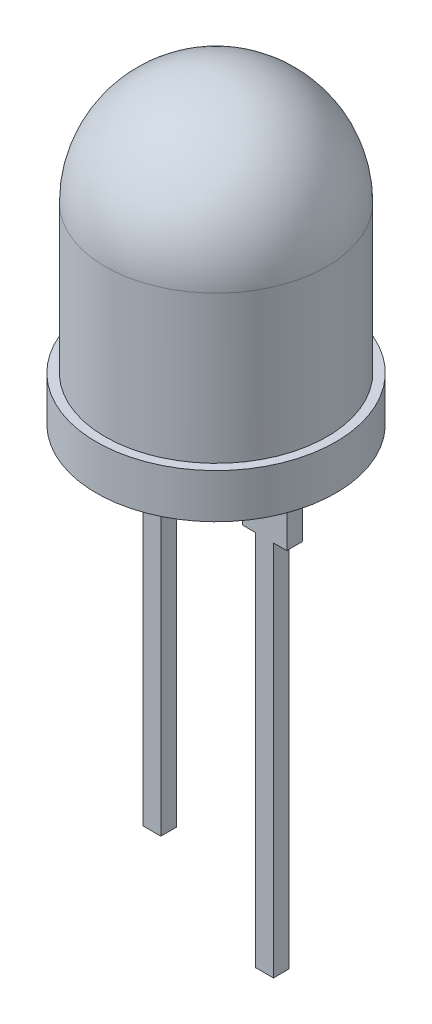
from build123d import *

# Parameters (mm, degrees)
BOSS_EXTRUDE1_DEPTH = 0.35


with BuildPart() as part:
    # Sketch1 → Revolve1 (revolve)
    with BuildSketch(Plane.XY):
        with BuildLine():
            Line((0, 0), (5.4, 0))
            Line((5.4, 0), (5.4, 2))
            Line((5.4, 2), (5, 2))
            Line((5, 2), (5, 8.65))
            ThreePointArc((5, 8.65), (3.535533906, 12.185533906), (0, 13.65))
            Line((0, 13.65), (0, 0))
        make_face()
    revolve(axis=Axis((0, 0, 0), (0, 1, 0)))

    # Sketch3 → Boss-Extrude1 (add, symmetric)
    with BuildSketch(Plane.XY):
        Polygon((1.54, -3), (1.54, 0), (3.54, 0), (3.54, -3), (2.94, -3), (2.94, -20), (2.14, -20), (2.14, -3), align=None)
        Polygon((-2.14, -17), (-2.94, -17), (-2.94, -3), (-3.54, -3), (-3.54, 0), (-1.54, 0), (-1.54, -3), (-2.14, -3), align=None)
    extrude(amount=BOSS_EXTRUDE1_DEPTH, both=True)


solid = part.part
